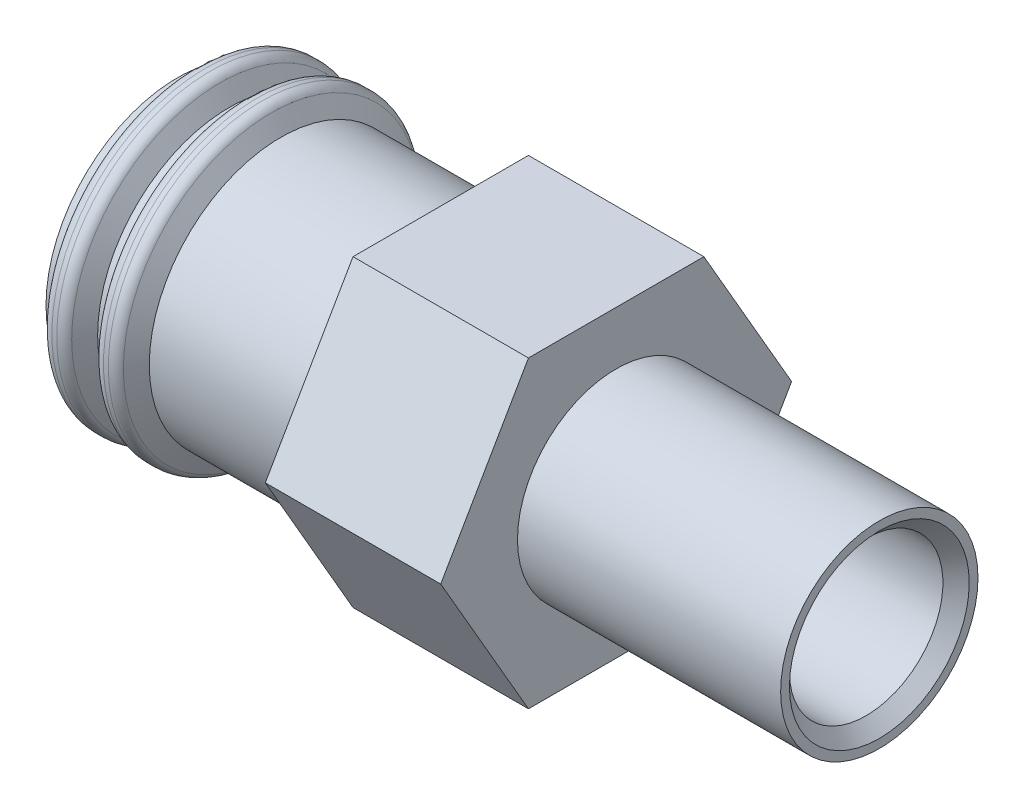
from build123d import *

# Parameters (mm, degrees)
CORTE_EXTRUS_O1_DEPTH = 4
FILETE1_R             = 0.25
FILETE2_R             = 0.25
CHANFRO1_SIZE         = 0.3


with BuildPart() as part:
    # Esboço1 → Revolução1 (revolve)
    with BuildSketch(Plane.XY):
        Polygon((-7.322649731, 3), (-7.122649731, 3), (-6.833974596, 3.5), (-6.433974596, 3.5), (-6.145299462, 3), (-2.5, 3), (-2.5, 4), (1.5, 4), (1.5, 2.25), (7.5, 2.25), (7.5, 1.75), (-3.200961894, 1.75), (-4.5, 2.5), (-8.5, 2.5), (-8.5, 3), (-8.3, 3), (-8.011324865, 3.5), (-7.611324865, 3.5), align=None)
    revolve(axis=Axis((-29.721905334, 0, 0), (1, 0, 0)))

    # Esboço2 → Corte-extrusão1 (cut)
    with BuildSketch(Plane(origin=(1.5, 0, 0), x_dir=(0, 0, -1), z_dir=(1, 0, 0))):
        with BuildLine():
            Line((-2, 3.464101615), (2, 3.464101615))
            ThreePointArc((2, 3.464101615), (0, 4), (-2, 3.464101615))
        make_face()
        with BuildLine():
            Line((-4, 0), (-2, 3.464101615))
            ThreePointArc((-2, 3.464101615), (-3.464101615, 2), (-4, 0))
        make_face()
        with BuildLine():
            ThreePointArc((-4, 0), (-3.464101615, -2), (-2, -3.464101615))
            Line((-2, -3.464101615), (-4, 0))
        make_face()
        with BuildLine():
            ThreePointArc((-2, -3.464101615), (0, -4), (2, -3.464101615))
            Line((2, -3.464101615), (-2, -3.464101615))
        make_face()
        with BuildLine():
            ThreePointArc((2, -3.464101615), (3.464101615, -2), (4, 0))
            Line((4, 0), (2, -3.464101615))
        make_face()
        with BuildLine():
            Line((2, 3.464101615), (4, 0))
            ThreePointArc((4, 0), (3.464101615, 2), (2, 3.464101615))
        make_face()
    extrude(amount=-CORTE_EXTRUS_O1_DEPTH, mode=Mode.SUBTRACT)

    # Filete1
    filete1_edges = [part.edges().sort_by_distance(p)[0] for p in [
        (-8.011324865, -3.5, 0),
        (-7.611324865, -3.5, 0),
    ]]
    fillet(filete1_edges, radius=FILETE1_R)

    # Filete2
    filete2_edges = [part.edges().sort_by_distance(p)[0] for p in [
        (-6.833974596, -3.5, 0),
        (-6.433974596, -3.5, 0),
    ]]
    fillet(filete2_edges, radius=FILETE2_R)

    # Chanfro1
    chanfro1_edges = [part.edges().sort_by_distance(p)[0] for p in [
        (7.5, -1.75, 0),
    ]]
    chamfer(chanfro1_edges, length=CHANFRO1_SIZE)


solid = part.part
